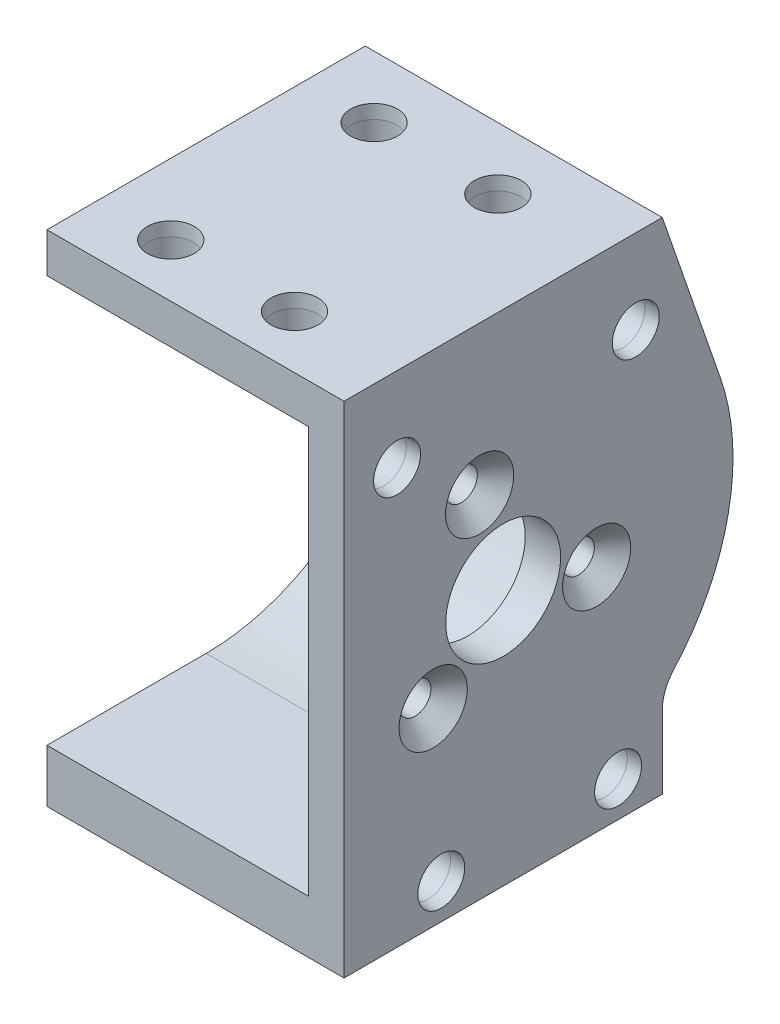
from build123d import *

# Parameters (mm, degrees)
MOTOR_SHELL_DEPTH                   = 33.6
MOTOR_MOUNT_DEPTH                   = 4
MOUNTING_HOLE_D                     = 3.6
MOUNTING_HOLE_CSINK_D               = 7.72
MOUNTING_HOLE_CSINK_ANGLE           = 90
HOLE_DUPLICATION_COUNT              = 3
SKETCH11_R                          = 6.5
SHAFT_BASE_CUTOUT_DEPTH             = 34.6
CSK_FOR_M3_INSERT_SFHCS1_AT_2_COUNT = 2
CSK_FOR_M3_INSERT_SFHCS1_AT_2_PITCH = 20
CSK_FOR_M3_INSERT_SFHCS1_AT_3_COUNT = 2
CSK_FOR_M3_INSERT_SFHCS1_AT_3_PITCH = 43.289721644
CSK_FOR_M3_INSERT_SFHCS1_AT_4_COUNT = 2
CSK_FOR_M3_INSERT_SFHCS1_AT_4_PITCH = 48.301138703
CSK_FOR_M3_INSERT_SFHCS2_AT_2_COUNT = 2
CSK_FOR_M3_INSERT_SFHCS2_AT_2_PITCH = 14
CSK_FOR_M3_INSERT_SFHCS2_AT_3_COUNT = 2
CSK_FOR_M3_INSERT_SFHCS2_AT_3_PITCH = 26.925824036
CSK_FOR_M3_INSERT_SFHCS2_AT_4_COUNT = 2
CSK_FOR_M3_INSERT_SFHCS2_AT_4_PITCH = 23
CUT_EXTRUDE1_DEPTH                  = 29.6
CSK_FOR_M3_INSERT_SFHCS3_AT_2_COUNT = 2
CSK_FOR_M3_INSERT_SFHCS3_AT_2_PITCH = 14
CSK_FOR_M3_INSERT_SFHCS3_AT_3_COUNT = 2
CSK_FOR_M3_INSERT_SFHCS3_AT_3_PITCH = 26.925824036
CSK_FOR_M3_INSERT_SFHCS3_AT_4_COUNT = 2
CSK_FOR_M3_INSERT_SFHCS3_AT_4_PITCH = 23
ADDITIONAL_STRUCTURE_DEPTH          = 2


with BuildPart() as part:
    # Motor Shell Profile → Motor Shell (new body)
    with BuildSketch(Plane(origin=(0, 0, 0), x_dir=(0, 0, -1), z_dir=(1, 0, 0))):
        with BuildLine():
            Line((0, 22), (-16, 22))
            Line((-16, 22), (-16, 27.5))
            Line((-16, 27.5), (18, 27.5))
            Line((18, 27.5), (24.57187505, 8.498409058))
            ThreePointArc((24.57187505, 8.498409058), (25.476909304, -5.189132134), (19.290322581, -17.432253289))
            ThreePointArc((19.290322581, -17.432253289), (18.333717374, -18.988556671), (18, -20.784609691))
            Line((18, -20.784609691), (18, -29))
            Line((18, -29), (-16, -29))
            Line((-16, -29), (-16, -22))
            Line((-16, -22), (0, -22))
            ThreePointArc((0, -22), (22, 0), (0, 22))
        make_face()
    extrude(amount=MOTOR_SHELL_DEPTH)

    # Sketch3 → Motor Mount (add)
    with BuildSketch(Plane(origin=(29.6, 0, 0), x_dir=(0, 0, -1), z_dir=(1, 0, 0))):
        with BuildLine():
            Line((0, 22), (-16, 22))
            Line((-16, 22), (-16, -22))
            Line((-16, -22), (0, -22))
            ThreePointArc((0, -22), (22, 0), (0, 22))
        make_face()
    extrude(amount=MOTOR_MOUNT_DEPTH)

    # Mounting Hole (through all)
    with Locations(Plane(origin=(33.6, 0, 0), x_dir=(0, 0, -1), z_dir=(1, 0, 0))):
        with Locations((10.573878655, -3.032010914)):
            mounting_hole = CounterSinkHole(MOUNTING_HOLE_D / 2, MOUNTING_HOLE_CSINK_D / 2, counter_sink_angle=MOUNTING_HOLE_CSINK_ANGLE)

    # Hole Duplication: Mounting Hole ×3 about axis
    hole_duplication_axis = Axis((0, 0, 0), (1, 0, 0))
    for i in range(1, HOLE_DUPLICATION_COUNT):
        add(mounting_hole.rotate(hole_duplication_axis, i * 360 / HOLE_DUPLICATION_COUNT), mode=Mode.SUBTRACT)

    # Sketch11 → Shaft Base Cutout (cut, through all)
    with BuildSketch(Plane(origin=(33.6, 0, 0), x_dir=(0, 0, -1), z_dir=(1, 0, 0))):
        Circle(SKETCH11_R)
    extrude(amount=-SHAFT_BASE_CUTOUT_DEPTH, mode=Mode.SUBTRACT)

    # Sketch15 → CSK for M3 Insert SFHCS1 (revolve, cut)
    with BuildSketch(Plane(origin=(33.6, -25, 7), x_dir=(0, 0, -1), z_dir=(0, 1, 0))):
        Polygon((0, 0), (0, 3.8), (2.55, 3.8), (2.55, 1.501569957), (2.655, 0), align=None)
    csk_for_m3_insert_sfhcs1 = revolve(axis=Axis((39.95, -25, 7), (-1, 0, 0)), mode=Mode.SUBTRACT)

    # CSK for M3 Insert SFHCS1 at 2: CSK for M3 Insert SFHCS1 ×2
    with Locations(*[(0, 0, -i * CSK_FOR_M3_INSERT_SFHCS1_AT_2_PITCH) for i in range(1, CSK_FOR_M3_INSERT_SFHCS1_AT_2_COUNT)]):
        add(csk_for_m3_insert_sfhcs1, mode=Mode.SUBTRACT)

    # CSK for M3 Insert SFHCS1 at 3: CSK for M3 Insert SFHCS1 ×2
    with Locations(*[Vector(0, 0.99330738, 0.115500858) * (i * CSK_FOR_M3_INSERT_SFHCS1_AT_3_PITCH) for i in range(1, CSK_FOR_M3_INSERT_SFHCS1_AT_3_COUNT)]):
        add(csk_for_m3_insert_sfhcs1, mode=Mode.SUBTRACT)

    # CSK for M3 Insert SFHCS1 at 4: CSK for M3 Insert SFHCS1 ×2
    with Locations(*[Vector(0, 0.890248163, -0.455475804) * (i * CSK_FOR_M3_INSERT_SFHCS1_AT_4_PITCH) for i in range(1, CSK_FOR_M3_INSERT_SFHCS1_AT_4_COUNT)]):
        add(csk_for_m3_insert_sfhcs1, mode=Mode.SUBTRACT)

    # Sketch18 → CSK for M3 Insert SFHCS2 (revolve, cut)
    with BuildSketch(Plane(origin=(22, 27.5, 12), x_dir=(0, 0, 1), z_dir=(1, 0, 0))):
        Polygon((0, 0), (0, 3.8), (2.55, 3.8), (2.55, 1.501569957), (2.655, 0), align=None)
    csk_for_m3_insert_sfhcs2 = revolve(axis=Axis((22, 33.85, 12), (0, -1, 0)), mode=Mode.SUBTRACT)

    # CSK for M3 Insert SFHCS2 at 2: CSK for M3 Insert SFHCS2 ×2
    with Locations(*[(-i * CSK_FOR_M3_INSERT_SFHCS2_AT_2_PITCH, 0, 0) for i in range(1, CSK_FOR_M3_INSERT_SFHCS2_AT_2_COUNT)]):
        add(csk_for_m3_insert_sfhcs2, mode=Mode.SUBTRACT)

    # CSK for M3 Insert SFHCS2 at 3: CSK for M3 Insert SFHCS2 ×2
    with Locations(*[Vector(-0.519946947, 0, -0.854198556) * (i * CSK_FOR_M3_INSERT_SFHCS2_AT_3_PITCH) for i in range(1, CSK_FOR_M3_INSERT_SFHCS2_AT_3_COUNT)]):
        add(csk_for_m3_insert_sfhcs2, mode=Mode.SUBTRACT)

    # CSK for M3 Insert SFHCS2 at 4: CSK for M3 Insert SFHCS2 ×2
    with Locations(*[(0, 0, -i * CSK_FOR_M3_INSERT_SFHCS2_AT_4_PITCH) for i in range(1, CSK_FOR_M3_INSERT_SFHCS2_AT_4_COUNT)]):
        add(csk_for_m3_insert_sfhcs2, mode=Mode.SUBTRACT)

    # Sketch25 → Cut-Extrude1 (cut)
    with BuildSketch(Plane.ZY):
        with BuildLine():
            Line((0, 23), (16, 23))
            Line((16, 23), (16, -23))
            Line((16, -23), (0, -23))
            ThreePointArc((0, -23), (-23, 0), (0, 23))
        make_face()
    extrude(amount=-CUT_EXTRUDE1_DEPTH, mode=Mode.SUBTRACT)

    # Sketch27 → CSK for M3 Insert SFHCS3 (revolve, cut)
    with BuildSketch(Plane(origin=(8, -29, 12), x_dir=(0, 0, -1), z_dir=(1, 0, 0))):
        Polygon((0, 0), (0, 3.8), (2.55, 3.8), (2.55, 1.501569957), (2.655, 0), align=None)
    csk_for_m3_insert_sfhcs3 = revolve(axis=Axis((8, -35.35, 12), (0, 1, 0)), mode=Mode.SUBTRACT)

    # CSK for M3 Insert SFHCS3 at 2: CSK for M3 Insert SFHCS3 ×2
    with Locations(*[(i * CSK_FOR_M3_INSERT_SFHCS3_AT_2_PITCH, 0, 0) for i in range(1, CSK_FOR_M3_INSERT_SFHCS3_AT_2_COUNT)]):
        add(csk_for_m3_insert_sfhcs3, mode=Mode.SUBTRACT)

    # CSK for M3 Insert SFHCS3 at 3: CSK for M3 Insert SFHCS3 ×2
    with Locations(*[Vector(0.519946947, 0, -0.854198556) * (i * CSK_FOR_M3_INSERT_SFHCS3_AT_3_PITCH) for i in range(1, CSK_FOR_M3_INSERT_SFHCS3_AT_3_COUNT)]):
        add(csk_for_m3_insert_sfhcs3, mode=Mode.SUBTRACT)

    # CSK for M3 Insert SFHCS3 at 4: CSK for M3 Insert SFHCS3 ×2
    with Locations(*[(0, 0, -i * CSK_FOR_M3_INSERT_SFHCS3_AT_4_PITCH) for i in range(1, CSK_FOR_M3_INSERT_SFHCS3_AT_4_COUNT)]):
        add(csk_for_m3_insert_sfhcs3, mode=Mode.SUBTRACT)

    # Sketch30 → Additional structure (add)
    with BuildSketch(Plane.XY.offset(16)):
        Polygon((0, 23), (29.6, 23), (29.6, -23), (0, -23), (0, -29), (33.6, -29), (33.6, 27.5), (0, 27.5), align=None)
    extrude(amount=ADDITIONAL_STRUCTURE_DEPTH)


solid = part.part
